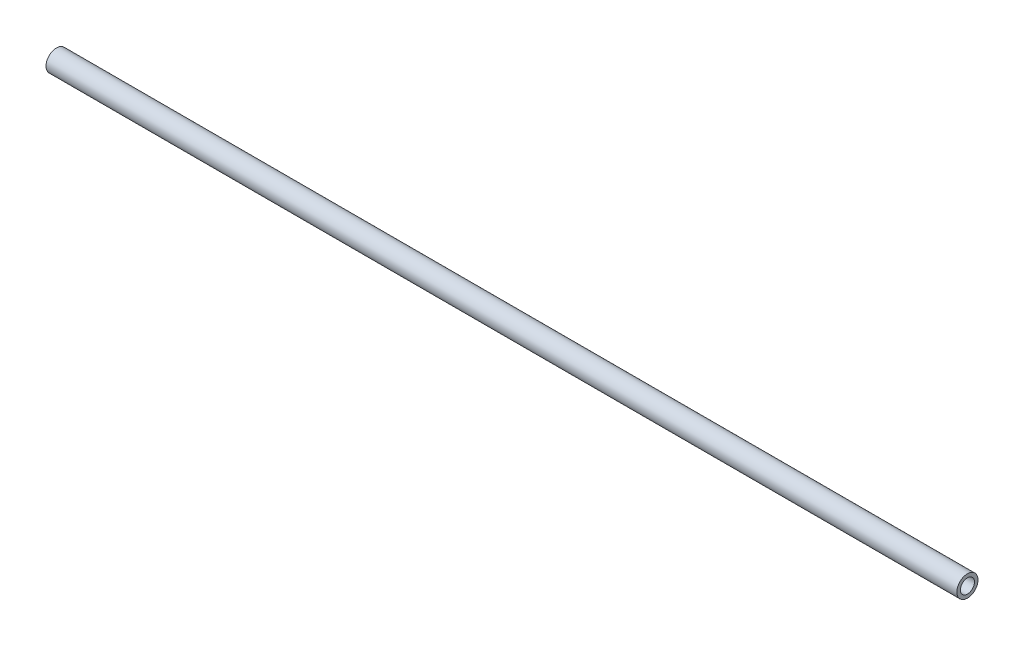
from build123d import *

# Parameters (mm, degrees)
SKETCH1_R      = 4.7625
SKETCH1_R_2    = 3.175
EXTRUDE1_DEPTH = 205.232


with BuildPart() as part:
    # Sketch1 → Extrude1 (new body, symmetric)
    with BuildSketch(Plane(origin=(0, 0, 0), x_dir=(0, 0, -1), z_dir=(1, 0, 0))):
        Circle(SKETCH1_R)
        Circle(SKETCH1_R_2, mode=Mode.SUBTRACT)
    extrude(amount=EXTRUDE1_DEPTH, both=True)


solid = part.part
